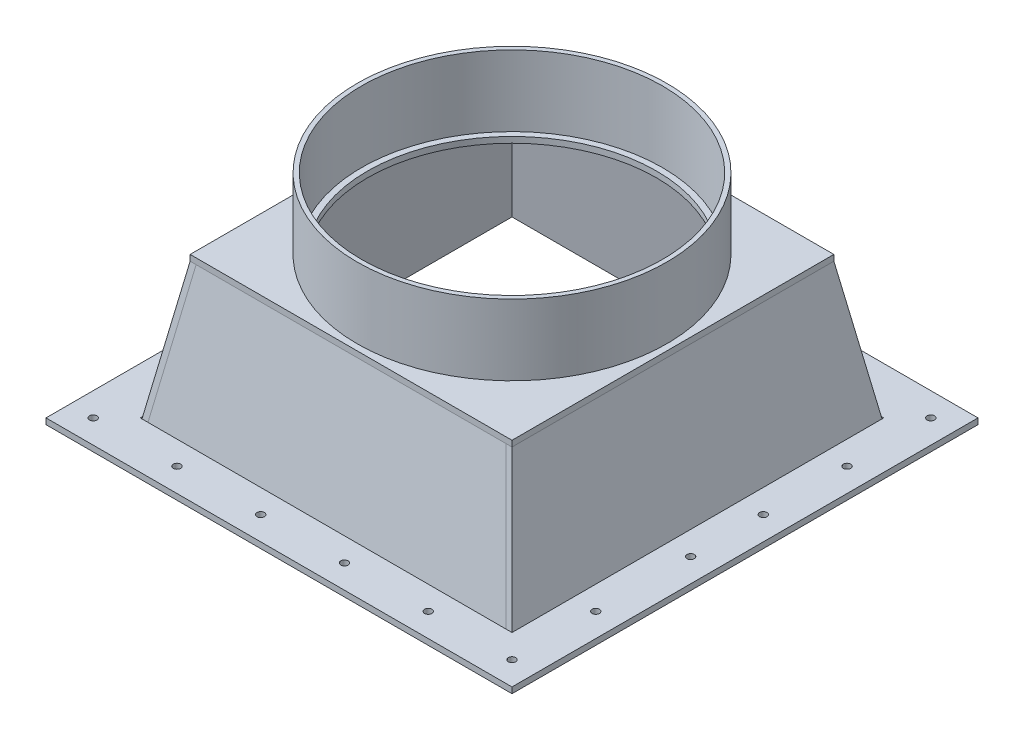
from build123d import *

# Parameters (mm, degrees)
SKETCH9_W                                = 501.649999896
SKETCH9_H                                = 6.35
BOSS_EXTRUDE6_DEPTH                      = 250.825
SKETCH10_W                               = 400.24591797
SKETCH10_H                               = 6.35
CUT_EXTRUDE3_DEPTH                       = 200.122959037
BOSS_EXTRUDE8_REACH                      = 252.825
BOSS_EXTRUDE8_DIRECTION_2_REACH          = 252.825
SKETCH12_W                               = 346.501454252
SKETCH12_H                               = 6.35
BOSS_EXTRUDE9_DEPTH                      = 173.250727158
BOSS_EXTRUDE10_REACH                     = 252.825
BOSS_EXTRUDE10_DIRECTION_2_REACH         = 252.825
CUT_EXTRUDE4_START                       = -250.825
CUT_EXTRUDE4_DEPTH                       = 501.65
SKETCH15_R                               = 166.6875
SKETCH15_R_2                             = 161.925
BOSS_EXTRUDE11_DEPTH                     = 76.2
SKETCH16_R                               = 155.575
CUT_EXTRUDE5_DEPTH                       = 159.75
SKETCH18_W                               = 3.96875
SKETCH18_H                               = 6.35
F_5_16_0_3125_DIAMETER_HOLE1_AT_2_COUNT  = 2
F_5_16_0_3125_DIAMETER_HOLE1_AT_2_PITCH  = 450.85
F_5_16_0_3125_DIAMETER_HOLE1_AT_3_COUNT  = 2
F_5_16_0_3125_DIAMETER_HOLE1_AT_3_PITCH  = 637.598184523
F_5_16_0_3125_DIAMETER_HOLE1_AT_4_COUNT  = 2
F_5_16_0_3125_DIAMETER_HOLE1_AT_4_PITCH  = 450.849999897
F_5_16_0_3125_DIAMETER_HOLE1_AT_5_COUNT  = 2
F_5_16_0_3125_DIAMETER_HOLE1_AT_5_PITCH  = 90.17
F_5_16_0_3125_DIAMETER_HOLE1_AT_6_COUNT  = 2
F_5_16_0_3125_DIAMETER_HOLE1_AT_6_PITCH  = 180.34
F_5_16_0_3125_DIAMETER_HOLE1_AT_7_COUNT  = 2
F_5_16_0_3125_DIAMETER_HOLE1_AT_7_PITCH  = 270.51
F_5_16_0_3125_DIAMETER_HOLE1_AT_8_COUNT  = 2
F_5_16_0_3125_DIAMETER_HOLE1_AT_8_PITCH  = 360.68
F_5_16_0_3125_DIAMETER_HOLE1_AT_9_COUNT  = 2
F_5_16_0_3125_DIAMETER_HOLE1_AT_9_PITCH  = 459.778589537
F_5_16_0_3125_DIAMETER_HOLE1_AT_10_COUNT = 2
F_5_16_0_3125_DIAMETER_HOLE1_AT_10_PITCH = 485.580310644
F_5_16_0_3125_DIAMETER_HOLE1_AT_11_COUNT = 2
F_5_16_0_3125_DIAMETER_HOLE1_AT_11_PITCH = 525.776932326
F_5_16_0_3125_DIAMETER_HOLE1_AT_12_COUNT = 2
F_5_16_0_3125_DIAMETER_HOLE1_AT_12_PITCH = 577.369712438
F_5_16_0_3125_DIAMETER_HOLE1_AT_13_COUNT = 2
F_5_16_0_3125_DIAMETER_HOLE1_AT_13_PITCH = 577.369712409
F_5_16_0_3125_DIAMETER_HOLE1_AT_14_COUNT = 2
F_5_16_0_3125_DIAMETER_HOLE1_AT_14_PITCH = 519.751082245
F_5_16_0_3125_DIAMETER_HOLE1_AT_15_COUNT = 2
F_5_16_0_3125_DIAMETER_HOLE1_AT_15_PITCH = 485.580310564
F_5_16_0_3125_DIAMETER_HOLE1_AT_16_COUNT = 2
F_5_16_0_3125_DIAMETER_HOLE1_AT_16_PITCH = 459.77858944
F_5_16_0_3125_DIAMETER_HOLE1_AT_17_COUNT = 2
F_5_16_0_3125_DIAMETER_HOLE1_AT_17_PITCH = 360.679999918
F_5_16_0_3125_DIAMETER_HOLE1_AT_18_COUNT = 2
F_5_16_0_3125_DIAMETER_HOLE1_AT_18_PITCH = 270.509999938
F_5_16_0_3125_DIAMETER_HOLE1_AT_19_COUNT = 2
F_5_16_0_3125_DIAMETER_HOLE1_AT_19_PITCH = 180.339999959
F_5_16_0_3125_DIAMETER_HOLE1_AT_20_COUNT = 2
F_5_16_0_3125_DIAMETER_HOLE1_AT_20_PITCH = 90.169999979


with BuildPart() as part:
    # Sketch9 → Boss-Extrude6 (new body, symmetric)
    with BuildSketch(Plane.XY):
        with Locations((0, 3.175)):
            Rectangle(SKETCH9_W, SKETCH9_H)
    extrude(amount=BOSS_EXTRUDE6_DEPTH, both=True)

    # Sketch10 → Cut-Extrude3 (cut, symmetric)
    with BuildSketch(Plane.XY):
        with Locations((0, 3.175)):
            Rectangle(SKETCH10_W, SKETCH10_H)
    extrude(amount=CUT_EXTRUDE3_DEPTH, both=True, mode=Mode.SUBTRACT)


with BuildPart() as body_2:

    # Boss-Extrude8: up to this face of the body (flat: up to its plane)
    boss_extrude8_end = Plane(part.part.faces().sort_by_distance((0, 3.175, -200.122959037))[0])
    # Sketch11 → Boss-Extrude8 (new body, up to the picked face)
    with BuildSketch(Plane.XY, mode=Mode.PRIVATE) as boss_extrude8_sk1:
        Polygon((-166.80276814, 152.4), (-193.675, 0), (-200.122958985, 0), (-173.250727126, 152.4), align=None)
    boss_extrude8_tool1 = split(extrude(boss_extrude8_sk1.sketch, amount=-BOSS_EXTRUDE8_REACH, mode=Mode.PRIVATE), bisect_by=boss_extrude8_end, keep=Keep.BOTH, mode=Mode.PRIVATE)
    add(boss_extrude8_tool1.solids().sort_by(Axis((-183.462864, 76.2, 0), (0, 0, -1)))[0])


    # Boss-Extrude8 direction 2: up to this face of the body (flat: up to its plane)
    boss_extrude8_direction_2_end = Plane(part.part.faces().sort_by_distance((0, 3.175, 200.122959037))[0])
    # Sketch11 → Boss-Extrude8 direction 2 (add, up to the picked face)
    with BuildSketch(Plane.XY, mode=Mode.PRIVATE) as boss_extrude8_direction_2_sk1:
        Polygon((-166.80276814, 152.4), (-193.675, 0), (-200.122958985, 0), (-173.250727126, 152.4), align=None)
    boss_extrude8_direction_2_tool1 = split(extrude(boss_extrude8_direction_2_sk1.sketch, amount=BOSS_EXTRUDE8_DIRECTION_2_REACH, mode=Mode.PRIVATE), bisect_by=boss_extrude8_direction_2_end, keep=Keep.BOTH, mode=Mode.PRIVATE)
    add(boss_extrude8_direction_2_tool1.solids().sort_by(Axis((-183.462864, 76.2, 0), (0, 0, 1)))[0])


with BuildPart() as body_3:
    # Mirror1: mirrored copy
    add(body_2.part.mirror(Plane(origin=(0, 0, 0), x_dir=(0, 0, 1), z_dir=(1, 0, 0))))


with BuildPart() as body_2_1:
    add(body_2.part)

    add(body_3.part)  # Boss-Extrude9 merges body 3
    # Sketch12 → Boss-Extrude9 (add, symmetric)
    with BuildSketch(Plane.XY):
        with Locations((0, 155.575)):
            Rectangle(SKETCH12_W, SKETCH12_H)
    extrude(amount=BOSS_EXTRUDE9_DEPTH, both=True)


with BuildPart() as body_3_2:

    # Boss-Extrude10: up to this face of the body (flat: up to its plane)
    boss_extrude10_end = Plane(body_2_1.part.faces().sort_by_distance((-180.23888407, 76.2, 0))[0])
    # Sketch13 → Boss-Extrude10 (new body, up to the picked face)
    with BuildSketch(Plane(origin=(0, 0, 0), x_dir=(0, 0, -1), z_dir=(1, 0, 0)), mode=Mode.PRIVATE) as boss_extrude10_sk1:
        Polygon((-173.250727158, 152.4), (-200.122959037, 0), (-193.675000051, 0), (-166.802768172, 152.4), align=None)
    boss_extrude10_tool1 = split(extrude(boss_extrude10_sk1.sketch, amount=-BOSS_EXTRUDE10_REACH, mode=Mode.PRIVATE), bisect_by=boss_extrude10_end, keep=Keep.BOTH, mode=Mode.PRIVATE)
    add(boss_extrude10_tool1.solids().sort_by(Axis((0, 76.2, 183.462864), (-1, 0, 0)))[0])
    # Sketch13 → Boss-Extrude10 (new body, up to the picked face)
    with BuildSketch(Plane(origin=(0, 0, 0), x_dir=(0, 0, -1), z_dir=(1, 0, 0)), mode=Mode.PRIVATE) as boss_extrude10_sk2:
        Polygon((166.802768172, 152.4), (173.250727158, 152.4), (200.122959037, 0), (193.675000051, 0), align=None)
    boss_extrude10_tool2 = split(extrude(boss_extrude10_sk2.sketch, amount=-BOSS_EXTRUDE10_REACH, mode=Mode.PRIVATE), bisect_by=boss_extrude10_end, keep=Keep.BOTH, mode=Mode.PRIVATE)
    add(boss_extrude10_tool2.solids().sort_by(Axis((0, 76.2, -183.462864), (-1, 0, 0)))[0])


    # Boss-Extrude10 direction 2: up to this face of the body (flat: up to its plane)
    boss_extrude10_direction_2_end = Plane(body_2_1.part.faces().sort_by_distance((180.23888407, 76.2, 0))[0])
    # Sketch13 → Boss-Extrude10 direction 2 (add, up to the picked face)
    with BuildSketch(Plane(origin=(0, 0, 0), x_dir=(0, 0, -1), z_dir=(1, 0, 0)), mode=Mode.PRIVATE) as boss_extrude10_direction_2_sk1:
        Polygon((-173.250727158, 152.4), (-200.122959037, 0), (-193.675000051, 0), (-166.802768172, 152.4), align=None)
    boss_extrude10_direction_2_tool1 = split(extrude(boss_extrude10_direction_2_sk1.sketch, amount=BOSS_EXTRUDE10_DIRECTION_2_REACH, mode=Mode.PRIVATE), bisect_by=boss_extrude10_direction_2_end, keep=Keep.BOTH, mode=Mode.PRIVATE)
    add(boss_extrude10_direction_2_tool1.solids().sort_by(Axis((0, 76.2, 183.462864), (1, 0, 0)))[0])
    # Sketch13 → Boss-Extrude10 direction 2 (add, up to the picked face)
    with BuildSketch(Plane(origin=(0, 0, 0), x_dir=(0, 0, -1), z_dir=(1, 0, 0)), mode=Mode.PRIVATE) as boss_extrude10_direction_2_sk2:
        Polygon((166.802768172, 152.4), (173.250727158, 152.4), (200.122959037, 0), (193.675000051, 0), align=None)
    boss_extrude10_direction_2_tool2 = split(extrude(boss_extrude10_direction_2_sk2.sketch, amount=BOSS_EXTRUDE10_DIRECTION_2_REACH, mode=Mode.PRIVATE), bisect_by=boss_extrude10_direction_2_end, keep=Keep.BOTH, mode=Mode.PRIVATE)
    add(boss_extrude10_direction_2_tool2.solids().sort_by(Axis((0, 76.2, -183.462864), (1, 0, 0)))[0])


with BuildPart() as body_2_2:
    add(body_2_1.part)

    # Sketch14 → Cut-Extrude4 (cut)
    with BuildSketch(Plane(origin=(0, 0, 0), x_dir=(0, 0, -1), z_dir=(1, 0, 0)).offset(CUT_EXTRUDE4_START)):
        Polygon((-173.250727158, 152.4), (-200.122959037, 152.4), (-200.122959037, 0), align=None)
        Polygon((173.250727158, 152.4), (200.122959037, 0), (200.122959037, 152.4), align=None)
    extrude(amount=CUT_EXTRUDE4_DEPTH, mode=Mode.SUBTRACT)

    # Sketch16 → Cut-Extrude5 (cut, through all)
    with BuildSketch(Plane(origin=(0, 158.75, 0), x_dir=(1, 0, 0), z_dir=(0, 1, 0))):
        with Locations(Location((0, 0, 0), (0, 0, 270))):  # turned: the seam where the file's is
            Circle(SKETCH16_R)
    extrude(amount=-CUT_EXTRUDE5_DEPTH, mode=Mode.SUBTRACT)


with BuildPart() as body_4:
    # Sketch15 → Boss-Extrude11 (new body)
    with BuildSketch(Plane(origin=(0, 158.75, 0), x_dir=(1, 0, 0), z_dir=(0, 1, 0))):
        with Locations(Location((0, 0, 0), (0, 0, 270))):  # turned: the seam where the file's is
            Circle(SKETCH15_R)
        with Locations(Location((0, 0, 0), (0, 0, 270))):  # turned: the seam where the file's is
            Circle(SKETCH15_R_2, mode=Mode.SUBTRACT)
    extrude(amount=BOSS_EXTRUDE11_DEPTH)


with BuildPart() as part_1:
    add(part.part)

    # Sketch18 → 5/16 (0.3125) Diameter Hole1 (revolve, cut)
    with BuildSketch(Plane(origin=(-225.424999948, 6.35, -225.425), x_dir=(0, 0, 1), z_dir=(1, 0, 0))):
        with Locations((1.984375, 3.175)):
            Rectangle(SKETCH18_W, SKETCH18_H)
    f_5_16_0_3125_diameter_hole1 = revolve(axis=Axis((-225.424999948, 12.7, -225.425), (0, -1, 0)), mode=Mode.SUBTRACT)

    # 5/16 (0.3125) Diameter Hole1 at 2: 5/16 (0.3125) Diameter Hole1 ×2
    with Locations(*[(0, 0, i * F_5_16_0_3125_DIAMETER_HOLE1_AT_2_PITCH) for i in range(1, F_5_16_0_3125_DIAMETER_HOLE1_AT_2_COUNT)]):
        add(f_5_16_0_3125_diameter_hole1, mode=Mode.SUBTRACT)

    # 5/16 (0.3125) Diameter Hole1 at 3: 5/16 (0.3125) Diameter Hole1 ×2
    with Locations(*[Vector(0.707106781, 0, 0.707106781) * (i * F_5_16_0_3125_DIAMETER_HOLE1_AT_3_PITCH) for i in range(1, F_5_16_0_3125_DIAMETER_HOLE1_AT_3_COUNT)]):
        add(f_5_16_0_3125_diameter_hole1, mode=Mode.SUBTRACT)

    # 5/16 (0.3125) Diameter Hole1 at 4: 5/16 (0.3125) Diameter Hole1 ×2
    with Locations(*[(i * F_5_16_0_3125_DIAMETER_HOLE1_AT_4_PITCH, 0, 0) for i in range(1, F_5_16_0_3125_DIAMETER_HOLE1_AT_4_COUNT)]):
        add(f_5_16_0_3125_diameter_hole1, mode=Mode.SUBTRACT)

    # 5/16 (0.3125) Diameter Hole1 at 5: 5/16 (0.3125) Diameter Hole1 ×2
    with Locations(*[(0, 0, i * F_5_16_0_3125_DIAMETER_HOLE1_AT_5_PITCH) for i in range(1, F_5_16_0_3125_DIAMETER_HOLE1_AT_5_COUNT)]):
        add(f_5_16_0_3125_diameter_hole1, mode=Mode.SUBTRACT)

    # 5/16 (0.3125) Diameter Hole1 at 6: 5/16 (0.3125) Diameter Hole1 ×2
    with Locations(*[(0, 0, i * F_5_16_0_3125_DIAMETER_HOLE1_AT_6_PITCH) for i in range(1, F_5_16_0_3125_DIAMETER_HOLE1_AT_6_COUNT)]):
        add(f_5_16_0_3125_diameter_hole1, mode=Mode.SUBTRACT)

    # 5/16 (0.3125) Diameter Hole1 at 7: 5/16 (0.3125) Diameter Hole1 ×2
    with Locations(*[(0, 0, i * F_5_16_0_3125_DIAMETER_HOLE1_AT_7_PITCH) for i in range(1, F_5_16_0_3125_DIAMETER_HOLE1_AT_7_COUNT)]):
        add(f_5_16_0_3125_diameter_hole1, mode=Mode.SUBTRACT)

    # 5/16 (0.3125) Diameter Hole1 at 8: 5/16 (0.3125) Diameter Hole1 ×2
    with Locations(*[(0, 0, i * F_5_16_0_3125_DIAMETER_HOLE1_AT_8_PITCH) for i in range(1, F_5_16_0_3125_DIAMETER_HOLE1_AT_8_COUNT)]):
        add(f_5_16_0_3125_diameter_hole1, mode=Mode.SUBTRACT)

    # 5/16 (0.3125) Diameter Hole1 at 9: 5/16 (0.3125) Diameter Hole1 ×2
    with Locations(*[Vector(0.196116135, 0, 0.980580676) * (i * F_5_16_0_3125_DIAMETER_HOLE1_AT_9_PITCH) for i in range(1, F_5_16_0_3125_DIAMETER_HOLE1_AT_9_COUNT)]):
        add(f_5_16_0_3125_diameter_hole1, mode=Mode.SUBTRACT)

    # 5/16 (0.3125) Diameter Hole1 at 10: 5/16 (0.3125) Diameter Hole1 ×2
    with Locations(*[Vector(0.371390676, 0, 0.928476691) * (i * F_5_16_0_3125_DIAMETER_HOLE1_AT_10_PITCH) for i in range(1, F_5_16_0_3125_DIAMETER_HOLE1_AT_10_COUNT)]):
        add(f_5_16_0_3125_diameter_hole1, mode=Mode.SUBTRACT)

    # 5/16 (0.3125) Diameter Hole1 at 11: 5/16 (0.3125) Diameter Hole1 ×2
    with Locations(*[Vector(0.514495755, 0, 0.857492926) * (i * F_5_16_0_3125_DIAMETER_HOLE1_AT_11_PITCH) for i in range(1, F_5_16_0_3125_DIAMETER_HOLE1_AT_11_COUNT)]):
        add(f_5_16_0_3125_diameter_hole1, mode=Mode.SUBTRACT)

    # 5/16 (0.3125) Diameter Hole1 at 12: 5/16 (0.3125) Diameter Hole1 ×2
    with Locations(*[Vector(0.624695047, 0, 0.78086881) * (i * F_5_16_0_3125_DIAMETER_HOLE1_AT_12_PITCH) for i in range(1, F_5_16_0_3125_DIAMETER_HOLE1_AT_12_COUNT)]):
        add(f_5_16_0_3125_diameter_hole1, mode=Mode.SUBTRACT)

    # 5/16 (0.3125) Diameter Hole1 at 13: 5/16 (0.3125) Diameter Hole1 ×2
    with Locations(*[Vector(0.780868809, 0, 0.624695048) * (i * F_5_16_0_3125_DIAMETER_HOLE1_AT_13_PITCH) for i in range(1, F_5_16_0_3125_DIAMETER_HOLE1_AT_13_COUNT)]):
        add(f_5_16_0_3125_diameter_hole1, mode=Mode.SUBTRACT)

    # 5/16 (0.3125) Diameter Hole1 at 14: 5/16 (0.3125) Diameter Hole1 ×2
    with Locations(*[Vector(0.867434461, 0, 0.49755146) * (i * F_5_16_0_3125_DIAMETER_HOLE1_AT_14_PITCH) for i in range(1, F_5_16_0_3125_DIAMETER_HOLE1_AT_14_COUNT)]):
        add(f_5_16_0_3125_diameter_hole1, mode=Mode.SUBTRACT)

    # 5/16 (0.3125) Diameter Hole1 at 15: 5/16 (0.3125) Diameter Hole1 ×2
    with Locations(*[Vector(0.928476691, 0, 0.371390676) * (i * F_5_16_0_3125_DIAMETER_HOLE1_AT_15_PITCH) for i in range(1, F_5_16_0_3125_DIAMETER_HOLE1_AT_15_COUNT)]):
        add(f_5_16_0_3125_diameter_hole1, mode=Mode.SUBTRACT)

    # 5/16 (0.3125) Diameter Hole1 at 16: 5/16 (0.3125) Diameter Hole1 ×2
    with Locations(*[Vector(0.980580676, 0, 0.196116135) * (i * F_5_16_0_3125_DIAMETER_HOLE1_AT_16_PITCH) for i in range(1, F_5_16_0_3125_DIAMETER_HOLE1_AT_16_COUNT)]):
        add(f_5_16_0_3125_diameter_hole1, mode=Mode.SUBTRACT)

    # 5/16 (0.3125) Diameter Hole1 at 17: 5/16 (0.3125) Diameter Hole1 ×2
    with Locations(*[(i * F_5_16_0_3125_DIAMETER_HOLE1_AT_17_PITCH, 0, 0) for i in range(1, F_5_16_0_3125_DIAMETER_HOLE1_AT_17_COUNT)]):
        add(f_5_16_0_3125_diameter_hole1, mode=Mode.SUBTRACT)

    # 5/16 (0.3125) Diameter Hole1 at 18: 5/16 (0.3125) Diameter Hole1 ×2
    with Locations(*[(i * F_5_16_0_3125_DIAMETER_HOLE1_AT_18_PITCH, 0, 0) for i in range(1, F_5_16_0_3125_DIAMETER_HOLE1_AT_18_COUNT)]):
        add(f_5_16_0_3125_diameter_hole1, mode=Mode.SUBTRACT)

    # 5/16 (0.3125) Diameter Hole1 at 19: 5/16 (0.3125) Diameter Hole1 ×2
    with Locations(*[(i * F_5_16_0_3125_DIAMETER_HOLE1_AT_19_PITCH, 0, 0) for i in range(1, F_5_16_0_3125_DIAMETER_HOLE1_AT_19_COUNT)]):
        add(f_5_16_0_3125_diameter_hole1, mode=Mode.SUBTRACT)

    # 5/16 (0.3125) Diameter Hole1 at 20: 5/16 (0.3125) Diameter Hole1 ×2
    with Locations(*[(i * F_5_16_0_3125_DIAMETER_HOLE1_AT_20_PITCH, 0, 0) for i in range(1, F_5_16_0_3125_DIAMETER_HOLE1_AT_20_COUNT)]):
        add(f_5_16_0_3125_diameter_hole1, mode=Mode.SUBTRACT)


solid = Compound([body_3_2.part, body_2_2.part, body_4.part, part_1.part])
